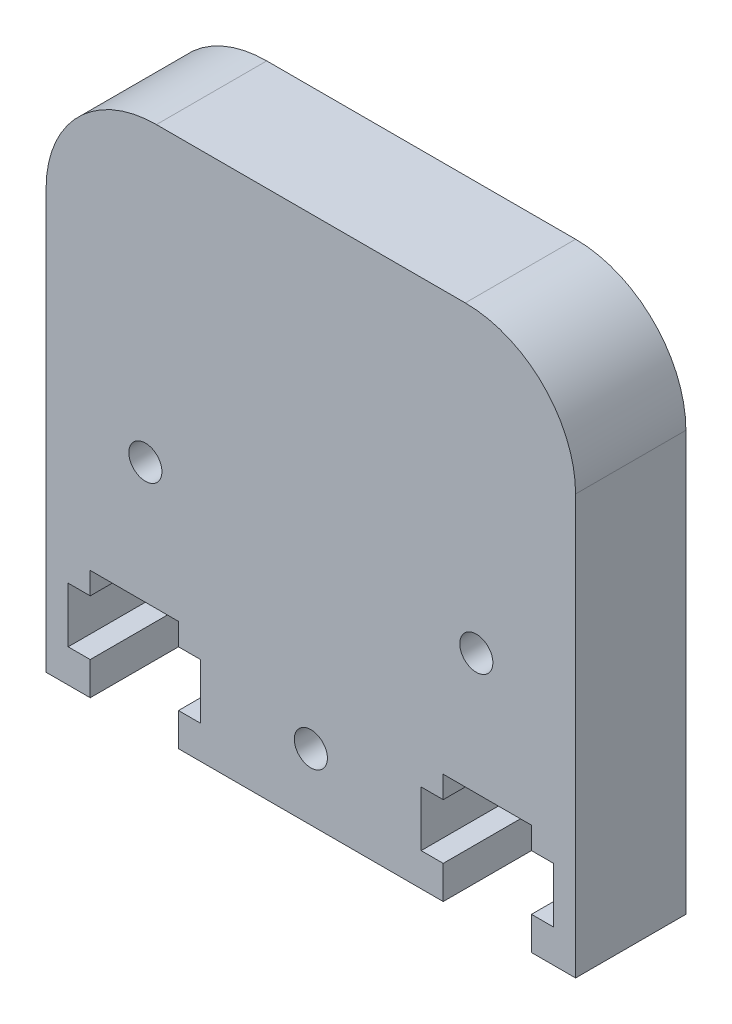
from build123d import *

# Parameters (mm, degrees)
SKETCH1_W           = 24
SKETCH1_H           = 24
SKETCH1_R           = 0.75
BOSS_EXTRUDE1_DEPTH = 5
FILLET1_R           = 5
CUT_EXTRUDE1_DEPTH  = 5


with BuildPart() as part:
    # Sketch1 → Boss-Extrude1 (new body)
    with BuildSketch(Plane.XY):
        Rectangle(SKETCH1_W, SKETCH1_H)
        with Locations((0, -9)):
            Circle(SKETCH1_R, mode=Mode.SUBTRACT)
        with Locations((-7.5, -1.5)):
            Circle(SKETCH1_R, mode=Mode.SUBTRACT)
        with Locations((7.5, -1.5)):
            Circle(SKETCH1_R, mode=Mode.SUBTRACT)
    extrude(amount=BOSS_EXTRUDE1_DEPTH)

    # Fillet1
    fillet1_edges = [part.edges().sort_by_distance(p)[0] for p in [
        (-12, 12, 2.5),
        (12, 12, 2.5),
    ]]
    fillet(fillet1_edges, radius=FILLET1_R)

    # Sketch2 → Cut-Extrude1 (cut)
    with BuildSketch(Plane.XY.offset(5)):
        Polygon((-10, -12), (-10, -10.5), (-11, -10.5), (-11, -8), (-10, -8), (-10, -7), (-6, -7), (-6, -8), (-5, -8), (-5, -10.5), (-6, -10.5), (-6, -12), align=None)
    cut_extrude1 = extrude(amount=-CUT_EXTRUDE1_DEPTH, mode=Mode.SUBTRACT)

    # Mirror1: Cut-Extrude1 across plane
    add(cut_extrude1.mirror(Plane(origin=(0, 0, 0), x_dir=(0, 0, 1), z_dir=(1, 0, 0))), mode=Mode.SUBTRACT)


solid = part.part
